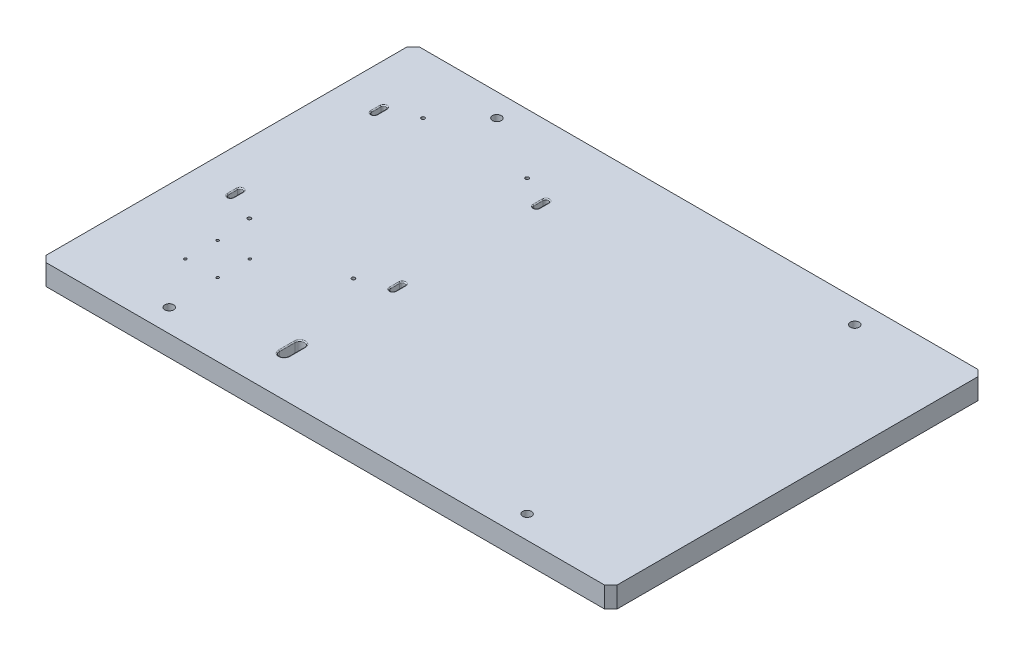
from build123d import *

# Parameters (mm, degrees)
SKETCH_1_W               = 549
SKETCH_1_H               = 359
EXTRUDE_1_DEPTH          = 20
HOLE_WIZARD_M10_1_D      = 8.5
HOLE_WIZARD_M4_1_D       = 3.3
CUT_EXTRUDE_1_DEPTH      = 1
CUT_EXTRUDE_1_DEPTH_BACK = 21
CHAMFER_1_SIZE           = 6
FILLET_2_R               = 1
CUT_EXTRUDE_4_DEPTH      = 20
HOLE_WIZARD_M3_2_D       = 2.5
HOLE_WIZARD_M3_2_DEPTH   = 20
FILLET_4_R               = 1
SKETCH_20_R              = 8.1
CUT_EXTRUDE_5_DEPTH      = 10


with BuildPart() as part:
    # 草图1 → 凸台-拉伸1 (new body)
    with BuildSketch(Plane(origin=(0, 0, 0), x_dir=(1, 0, 0), z_dir=(0, 1, 0))):
        with Locations((214.498740765, -144.65170767)):
            Rectangle(SKETCH_1_W, SKETCH_1_H)
    extrude(amount=EXTRUDE_1_DEPTH)

    # M10 螺纹孔1 (through all)
    with Locations(Plane(origin=(0, 20, 0), x_dir=(1, 0, 0), z_dir=(0, 1, 0))):
        with Locations((386.498740765, -302.15170767), (42.498740765, 12.84829233), (386.498740765, 12.84829233), (42.498740765, -302.15170767)):
            Hole(HOLE_WIZARD_M10_1_D / 2)

    # M4 螺纹孔1 (through all)
    with Locations(Plane(origin=(0, 20, 0), x_dir=(1, 0, 0), z_dir=(0, 1, 0))):
        with Locations((6.998740765, -189.65170767), (6.998740765, -22.65170767), (106.998740765, -22.65170767), (106.998740765, -189.65170767)):
            Hole(HOLE_WIZARD_M4_1_D / 2)

    # 草图9 → 切除-拉伸1 (cut, two sides)
    with BuildSketch(Plane(origin=(0, 20, 0), x_dir=(1, 0, 0), z_dir=(0, 1, 0))) as cut_extrude_1_sk:
        with BuildLine():
            Line((-18.501259235, -32.65170767), (-18.501259235, -41.65170767))
            ThreePointArc((-18.501259235, -41.65170767), (-21.001259235, -44.15170767), (-23.501259235, -41.65170767))
            Line((-23.501259235, -41.65170767), (-23.501259235, -32.65170767))
            ThreePointArc((-23.501259235, -32.65170767), (-21.001259235, -30.15170767), (-18.501259235, -32.65170767))
        make_face()
        with BuildLine():
            Line((132.498740765, -32.65170767), (132.498740765, -41.65170767))
            ThreePointArc((132.498740765, -41.65170767), (134.998740765, -44.15170767), (137.498740765, -41.65170767))
            Line((137.498740765, -41.65170767), (137.498740765, -32.65170767))
            ThreePointArc((137.498740765, -32.65170767), (134.998740765, -30.15170767), (132.498740765, -32.65170767))
        make_face()
        with BuildLine():
            Line((132.498740765, -179.65170767), (132.498740765, -170.65170767))
            ThreePointArc((132.498740765, -170.65170767), (134.998740765, -168.15170767), (137.498740765, -170.65170767))
            Line((137.498740765, -170.65170767), (137.498740765, -179.65170767))
            ThreePointArc((137.498740765, -179.65170767), (134.998740765, -182.15170767), (132.498740765, -179.65170767))
        make_face()
        with BuildLine():
            Line((-18.501259235, -179.65170767), (-18.501259235, -170.65170767))
            ThreePointArc((-18.501259235, -170.65170767), (-21.001259235, -168.15170767), (-23.501259235, -170.65170767))
            Line((-23.501259235, -170.65170767), (-23.501259235, -179.65170767))
            ThreePointArc((-23.501259235, -179.65170767), (-21.001259235, -182.15170767), (-18.501259235, -179.65170767))
        make_face()
    extrude(amount=CUT_EXTRUDE_1_DEPTH, mode=Mode.SUBTRACT)
    extrude(cut_extrude_1_sk.sketch, amount=-CUT_EXTRUDE_1_DEPTH_BACK, mode=Mode.SUBTRACT)

    # 倒角1
    chamfer_1_edges = [part.edges().sort_by_distance(p)[0] for p in [
        (-60.001259235, 10, -34.84829233),
        (488.998740765, 10, -34.84829233),
        (488.998740765, 10, 324.15170767),
        (-60.001259235, 10, 324.15170767),
    ]]
    chamfer(chamfer_1_edges, length=CHAMFER_1_SIZE)

    # 圆角2
    fillet_2_edges = [part.edges().sort_by_distance(p)[0] for p in [
        (134.998740765, 20, 44.15170767),
        (137.498740765, 20, 37.15170767),
        (-21.001259235, 0, 30.15170767),
        (-18.501259235, 0, 37.15170767),
        (-21.001259235, 0, 44.15170767),
        (-23.501259235, 0, 37.15170767),
        (-21.001259235, 20, 30.15170767),
        (-23.501259235, 20, 37.15170767),
        (-21.001259235, 20, 44.15170767),
        (-18.501259235, 20, 37.15170767),
        (-21.001259235, 0, 182.15170767),
        (-23.501259235, 0, 175.15170767),
        (-21.001259235, 0, 168.15170767),
        (-18.501259235, 0, 175.15170767),
        (-21.001259235, 20, 182.15170767),
        (-18.501259235, 20, 175.15170767),
        (-21.001259235, 20, 168.15170767),
        (-23.501259235, 20, 175.15170767),
        (134.998740765, 0, 182.15170767),
        (132.498740765, 0, 175.15170767),
        (134.998740765, 0, 168.15170767),
        (137.498740765, 0, 175.15170767),
        (134.998740765, 20, 182.15170767),
        (137.498740765, 20, 175.15170767),
        (134.998740765, 20, 168.15170767),
        (132.498740765, 20, 175.15170767),
        (134.998740765, 0, 30.15170767),
        (137.498740765, 0, 37.15170767),
        (134.998740765, 0, 44.15170767),
        (132.498740765, 0, 37.15170767),
        (134.998740765, 20, 30.15170767),
        (132.498740765, 20, 37.15170767),
    ]]
    fillet(fillet_2_edges, radius=FILLET_2_R)

    # 草图16 → 切除-拉伸4 (cut)
    with BuildSketch(Plane.XZ):
        with BuildLine():
            Line((131.498740765, 270.182944489), (131.498740765, 285.182944489))
            ThreePointArc((131.498740765, 285.182944489), (135.998740765, 289.682944489), (140.498740765, 285.182944489))
            Line((140.498740765, 285.182944489), (140.498740765, 270.182944489))
            ThreePointArc((140.498740765, 270.182944489), (135.998740765, 265.682944489), (131.498740765, 270.182944489))
        make_face()
    extrude(amount=-CUT_EXTRUDE_4_DEPTH, mode=Mode.SUBTRACT)

    # M3 螺纹孔2
    with Locations(Plane.XZ):
        with Locations((9.998740765, 254.15170767), (40.998740765, 254.15170767), (9.998740765, 223.15170767), (40.998740765, 223.15170767)):
            Hole(HOLE_WIZARD_M3_2_D / 2, depth=HOLE_WIZARD_M3_2_DEPTH)

    # 圆角4
    fillet_4_edges = [part.edges().sort_by_distance(p)[0] for p in [
        (135.998740765, 0, 265.682944489),
        (140.498740765, 0, 277.682944489),
        (135.998740765, 0, 289.682944489),
        (131.498740765, 0, 277.682944489),
        (140.498740765, 20, 277.682944489),
        (135.998740765, 20, 289.682944489),
        (131.498740765, 20, 277.682944489),
        (135.998740765, 20, 265.682944489),
    ]]
    fillet(fillet_4_edges, radius=FILLET_4_R)

    # 草图20 → 切除-拉伸5 (cut)
    with BuildSketch(Plane.XZ):
        with Locations((42.498740765, 302.15170767)):
            Circle(SKETCH_20_R)
        with Locations((386.498740765, 302.15170767)):
            Circle(SKETCH_20_R)
        with Locations((386.498740765, -12.84829233)):
            Circle(SKETCH_20_R)
        with Locations((42.498740765, -12.84829233)):
            Circle(SKETCH_20_R)
    extrude(amount=-CUT_EXTRUDE_5_DEPTH, mode=Mode.SUBTRACT)


solid = part.part
